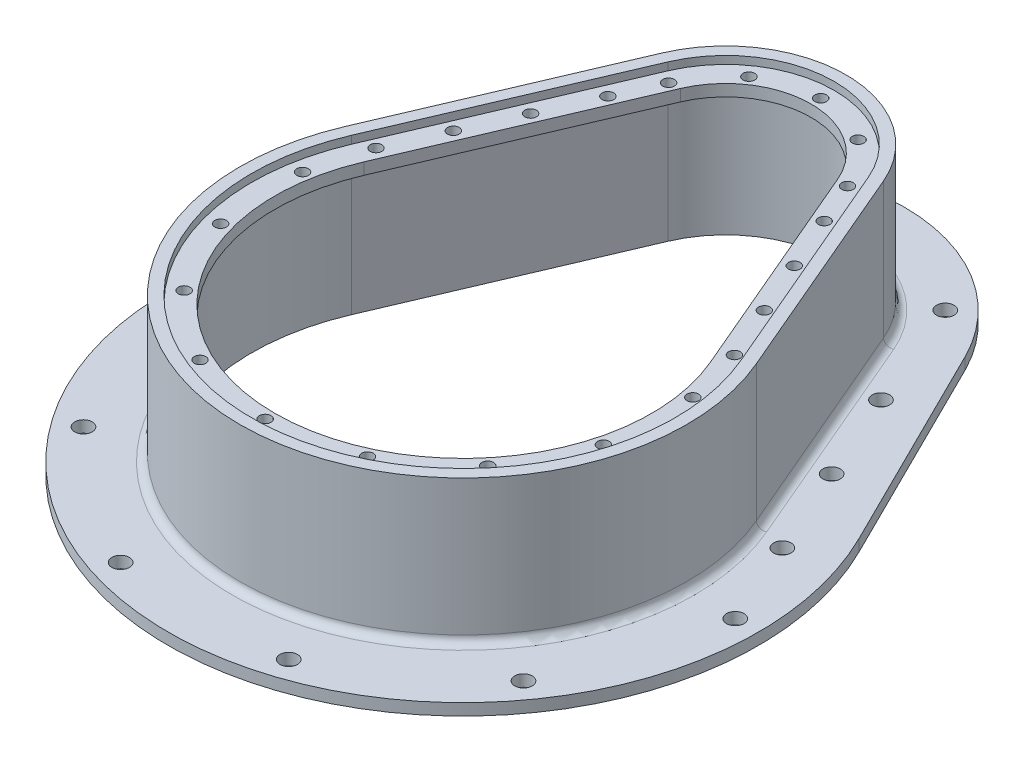
from build123d import *

# Parameters (mm, degrees)
SKETCH1_R           = 2.25
BOSS_EXTRUDE1_DEPTH = 3
BOSS_EXTRUDE2_DEPTH = 40
BOSS_EXTRUDE3_START = -5
BOSS_EXTRUDE3_DEPTH = 3
SKETCH6_R           = 1.5
CUT_EXTRUDE1_DEPTH  = 142.782403704
FILLET1_R           = 2


with BuildPart() as part:
    # Sketch1 → Boss-Extrude1 (new body)
    with BuildSketch(Plane(origin=(0, 0, 0), x_dir=(1, 0, 0), z_dir=(0, 1, 0))):
        with BuildLine():
            Line((68.081287652, 33.777777778), (41.207095158, 87.944444444))
            ThreePointArc((41.207095158, 87.944444444), (0, 113.5), (-41.207095158, 87.944444444))
            Line((-41.207095158, 87.944444444), (-68.081287652, 33.777777778))
            ThreePointArc((-68.081287652, 33.777777778), (0, -76), (68.081287652, 33.777777778))
        make_face()
        with Locations((-56.631189606, -41.14496766)):
            Circle(SKETCH1_R, mode=Mode.SUBTRACT)
        with Locations((-21.631189606, -66.573956141)):
            Circle(SKETCH1_R, mode=Mode.SUBTRACT)
        with Locations((-70, 0)):
            Circle(SKETCH1_R, mode=Mode.SUBTRACT)
        with Locations((21.631189606, -66.573956141)):
            Circle(SKETCH1_R, mode=Mode.SUBTRACT)
        with Locations((56.631189606, -41.14496766)):
            Circle(SKETCH1_R, mode=Mode.SUBTRACT)
        with Locations((70, 0)):
            Circle(SKETCH1_R, mode=Mode.SUBTRACT)
        with Locations((-60.306923303, 21.809422569)):
            Circle(SKETCH1_R, mode=Mode.SUBTRACT)
        with Locations((-50.153461651, 44.654711284)):
            Circle(SKETCH1_R, mode=Mode.SUBTRACT)
        with Locations((-40, 67.5)):
            Circle(SKETCH1_R, mode=Mode.SUBTRACT)
        with Locations((-28.284271247, 95.784271247)):
            Circle(SKETCH1_R, mode=Mode.SUBTRACT)
        with Locations((0, 107.5)):
            Circle(SKETCH1_R, mode=Mode.SUBTRACT)
        with BuildLine():
            Line((-52.883467924, 22.574074074), (-28.511087055, 79.67037037))
            ThreePointArc((-28.511087055, 79.67037037), (0, 98.5), (28.511087055, 79.67037037))
            Line((28.511087055, 79.67037037), (52.883467924, 22.574074074))
            ThreePointArc((52.883467924, 22.574074074), (0, -57.5), (-52.883467924, 22.574074074))
        make_face(mode=Mode.SUBTRACT)
        with Locations((60.306923303, 21.809422569)):
            Circle(SKETCH1_R, mode=Mode.SUBTRACT)
        with Locations((50.153461651, 44.654711284)):
            Circle(SKETCH1_R, mode=Mode.SUBTRACT)
        with Locations((28.284271247, 95.784271247)):
            Circle(SKETCH1_R, mode=Mode.SUBTRACT)
        with Locations((40, 67.5)):
            Circle(SKETCH1_R, mode=Mode.SUBTRACT)
    extrude(amount=BOSS_EXTRUDE1_DEPTH)

    # Sketch1_3 → Boss-Extrude2 (add)
    with BuildSketch(Plane(origin=(0, 0, 0), x_dir=(1, 0, 0), z_dir=(0, 1, 0))):
        with BuildLine():
            ThreePointArc((28.511087055, 79.67037037), (0, 98.5), (-28.511087055, 79.67037037))
            Line((-28.511087055, 79.67037037), (-52.883467924, 22.574074074))
            ThreePointArc((-52.883467924, 22.574074074), (0, -57.5), (52.883467924, 22.574074074))
            Line((52.883467924, 22.574074074), (28.511087055, 79.67037037))
        make_face()
        with BuildLine():
            Line((-50.124330467, 21.396296296), (-25.751949598, 78.492592593))
            ThreePointArc((-25.751949598, 78.492592593), (0, 95.5), (25.751949598, 78.492592593))
            Line((25.751949598, 78.492592593), (50.124330467, 21.396296296))
            ThreePointArc((50.124330467, 21.396296296), (0, -54.5), (-50.124330467, 21.396296296))
        make_face(mode=Mode.SUBTRACT)
    extrude(amount=BOSS_EXTRUDE2_DEPTH)

    # Sketch5 → Boss-Extrude3 (add)
    with BuildSketch(Plane(origin=(0, 40, 0), x_dir=(1, 0, 0), z_dir=(0, 1, 0)).offset(BOSS_EXTRUDE3_START)):
        with BuildLine():
            Line((25.751949598, 78.492592593), (50.124330467, 21.396296296))
            ThreePointArc((50.124330467, 21.396296296), (0, -54.5), (-50.124330467, 21.396296296))
            Line((-50.124330467, 21.396296296), (-25.751949598, 78.492592593))
            ThreePointArc((-25.751949598, 78.492592593), (0, 95.5), (25.751949598, 78.492592593))
        make_face()
        with BuildLine():
            Line((-20.233674684, 76.137037037), (-44.606055554, 19.040740741))
            ThreePointArc((-44.606055554, 19.040740741), (0, -48.5), (44.606055554, 19.040740741))
            Line((44.606055554, 19.040740741), (20.233674684, 76.137037037))
            ThreePointArc((20.233674684, 76.137037037), (0, 89.5), (-20.233674684, 76.137037037))
        make_face(mode=Mode.SUBTRACT)
    extrude(amount=BOSS_EXTRUDE3_DEPTH)

    # Sketch6 → Cut-Extrude1 (cut, through all)
    with BuildSketch(Plane(origin=(0, 38, 0), x_dir=(1, 0, 0), z_dir=(0, 1, 0))):
        with Locations((0, -51)):
            Circle(SKETCH6_R)
        with Locations((0, 92)):
            Circle(SKETCH6_R)
        with Locations((14.052622691, 87.569225085)):
            Circle(SKETCH6_R)
        with Locations((23.022469209, 75.879493511)):
            Circle(SKETCH6_R)
        with Locations((21.553531349, -46.221697139)):
            Circle(SKETCH6_R)
        with Locations((39.068266599, -32.782168094)):
            Circle(SKETCH6_R)
        with Locations((49.262217141, -13.1997713)):
            Circle(SKETCH6_R)
        with Locations((50.225195404, 8.856057061)):
            Circle(SKETCH6_R)
        with Locations((27.835315177, 65.055939465)):
            Circle(SKETCH6_R)
        with Locations((33.935175216, 51.257307943)):
            Circle(SKETCH6_R)
        with Locations((40.035035255, 37.45867642)):
            Circle(SKETCH6_R)
        with Locations((46.134895294, 23.660044897)):
            Circle(SKETCH6_R)
        with Locations((-46.134895294, 23.660044897)):
            Circle(SKETCH6_R)
        with Locations((-40.035035255, 37.45867642)):
            Circle(SKETCH6_R)
        with Locations((-33.935175216, 51.257307943)):
            Circle(SKETCH6_R)
        with Locations((-27.835315177, 65.055939465)):
            Circle(SKETCH6_R)
        with Locations((-50.225195404, 8.856057061)):
            Circle(SKETCH6_R)
        with Locations((-49.262217141, -13.1997713)):
            Circle(SKETCH6_R)
        with Locations((-39.068266599, -32.782168094)):
            Circle(SKETCH6_R)
        with Locations((-21.553531349, -46.221697139)):
            Circle(SKETCH6_R)
        with Locations((-23.022469209, 75.879493511)):
            Circle(SKETCH6_R)
        with Locations((-14.052622691, 87.569225085)):
            Circle(SKETCH6_R)
    extrude(amount=-CUT_EXTRUDE1_DEPTH, mode=Mode.SUBTRACT)

    # Fillet1
    fillet1_edges = [part.edges().sort_by_distance(p)[0] for p in [
        (-40.69727749, 3, -51.122222222),
        (0, 3, -98.5),
        (40.69727749, 3, -51.122222222),
        (0, 3, 57.5),
    ]]
    fillet(fillet1_edges, radius=FILLET1_R)


solid = part.part
